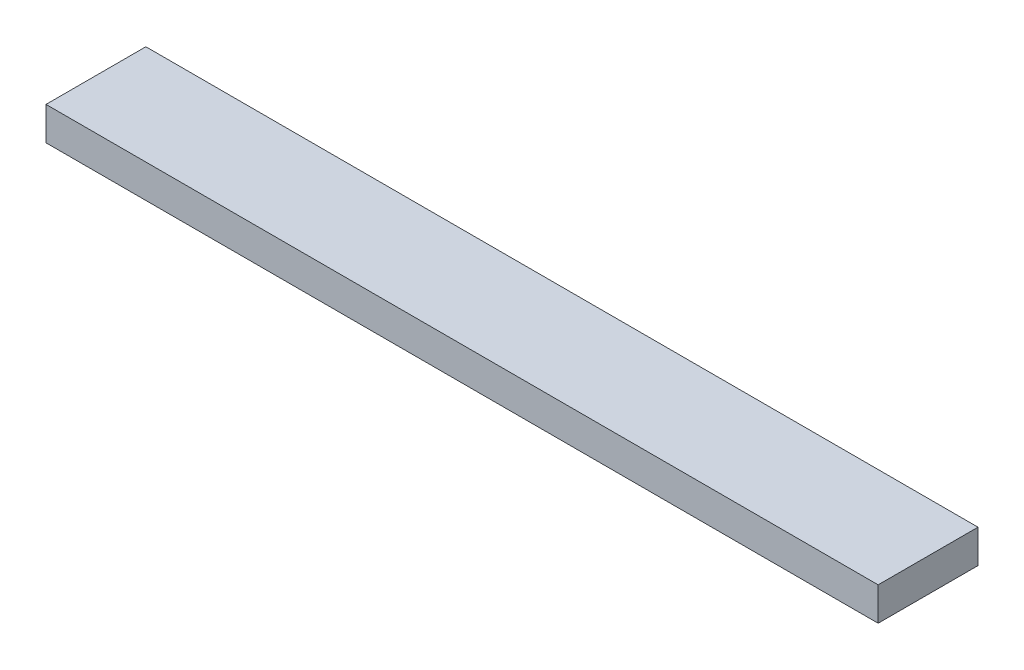
from build123d import *

# Parameters (mm, degrees)
SKETCH1_W           = 500
SKETCH1_H           = 60
BOSS_EXTRUDE1_DEPTH = 20


with BuildPart() as part:
    # Sketch1 → Boss-Extrude1 (new body)
    with BuildSketch(Plane(origin=(0, 0, 0), x_dir=(1, 0, 0), z_dir=(0, 1, 0))):
        Rectangle(SKETCH1_W, SKETCH1_H)
    extrude(amount=BOSS_EXTRUDE1_DEPTH)


solid = part.part
